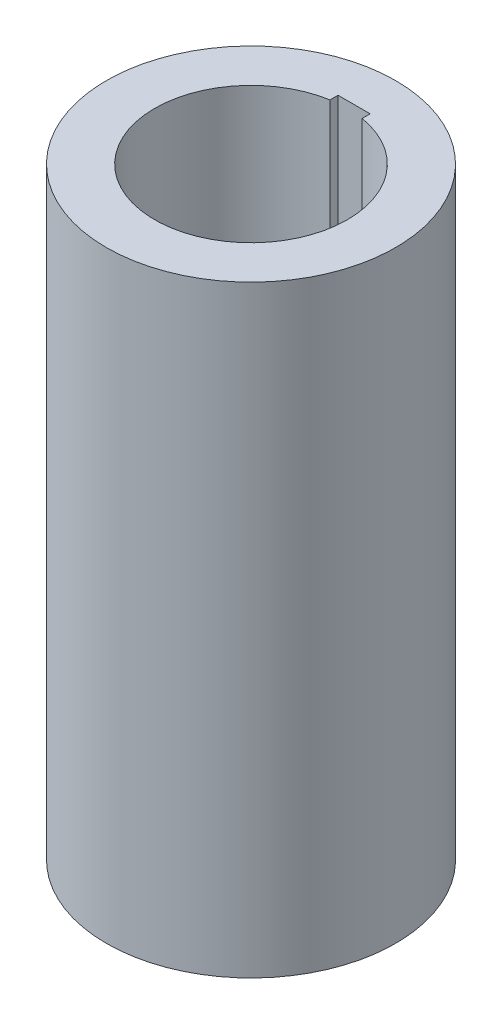
from build123d import *

# Parameters (mm, degrees)
SKETCH1_R           = 18
BOSS_EXTRUDE1_DEPTH = 75


with BuildPart() as part:
    # Sketch1 → Boss-Extrude1 (new body)
    with BuildSketch(Plane(origin=(0, 0, 0), x_dir=(1, 0, 0), z_dir=(0, 1, 0))):
        Circle(SKETCH1_R)
        with BuildLine():
            Line((-2, 11.832159566), (-2, 12.832159566))
            Line((-2, 12.832159566), (2, 12.832159566))
            Line((2, 12.832159566), (2, 11.832159566))
            ThreePointArc((2, 11.832159566), (9.16515139, 7.745966692), (12, 0))
            ThreePointArc((12, 0), (-7.745966692, -9.16515139), (-2, 11.832159566))
        make_face(mode=Mode.SUBTRACT)
    extrude(amount=BOSS_EXTRUDE1_DEPTH)


solid = part.part
